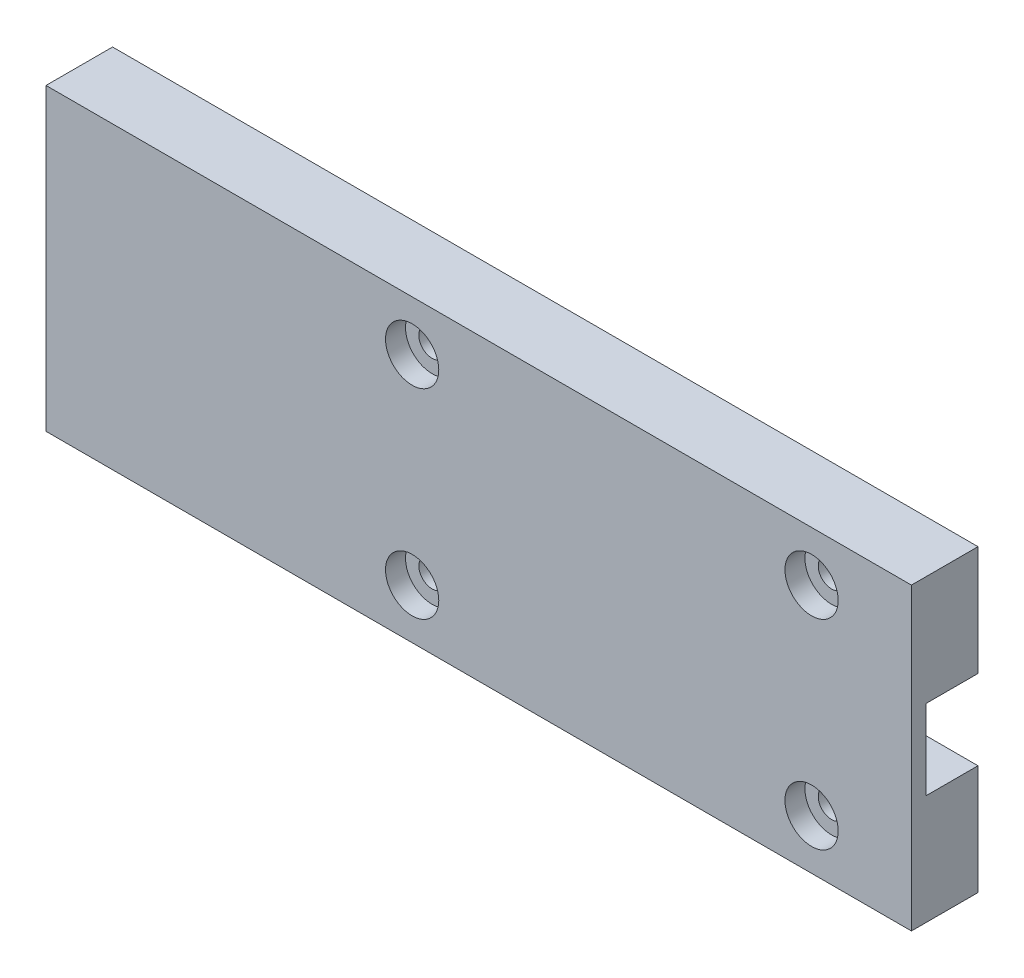
from build123d import *

# Parameters (mm, degrees)
SKETCH1_W           = 130
SKETCH1_H           = 45
BOSS_EXTRUDE1_DEPTH = 10
SKETCH2_W           = 110
SKETCH2_H           = 12
CUT_EXTRUDE1_DEPTH  = 7.8
SKETCH4_R           = 2
CUT_EXTRUDE3_DEPTH  = 11
SKETCH5_R           = 4
CUT_EXTRUDE4_DEPTH  = 3
SKETCH6_W           = 41
SKETCH6_H           = 41
CUT_EXTRUDE5_DEPTH  = 7.8


with BuildPart() as part:
    # Sketch1 → Boss-Extrude1 (new body)
    with BuildSketch(Plane.XY):
        with Locations((65, 22.5)):
            Rectangle(SKETCH1_W, SKETCH1_H)
    extrude(amount=BOSS_EXTRUDE1_DEPTH)

    # Sketch2 → Cut-Extrude1 (cut)
    with BuildSketch(Plane(origin=(0, 0, 0), x_dir=(-1, 0, 0), z_dir=(0, 0, -1))):
        with Locations((-75, 22.5)):
            Rectangle(SKETCH2_W, SKETCH2_H)
    extrude(amount=-CUT_EXTRUDE1_DEPTH, mode=Mode.SUBTRACT)

    # Sketch4 → Cut-Extrude3 (cut, through all)
    with BuildSketch(Plane.XY.offset(10)):
        with Locations((55, 37.5)):
            Circle(SKETCH4_R)
        with Locations((115, 37.5)):
            Circle(SKETCH4_R)
        with Locations((115, 7.5)):
            Circle(SKETCH4_R)
        with Locations((55, 7.5)):
            Circle(SKETCH4_R)
    extrude(amount=-CUT_EXTRUDE3_DEPTH, mode=Mode.SUBTRACT)

    # Sketch5 → Cut-Extrude4 (cut)
    with BuildSketch(Plane.XY.offset(10)):
        with Locations((55, 37.5)):
            Circle(SKETCH5_R)
        with Locations((115, 37.5)):
            Circle(SKETCH5_R)
        with Locations((115, 7.5)):
            Circle(SKETCH5_R)
        with Locations((55, 7.5)):
            Circle(SKETCH5_R)
    extrude(amount=-CUT_EXTRUDE4_DEPTH, mode=Mode.SUBTRACT)

    # Sketch6 → Cut-Extrude5 (cut)
    with BuildSketch(Plane(origin=(0, 0, 0), x_dir=(-1, 0, 0), z_dir=(0, 0, -1))):
        with Locations((-27, 22.5)):
            Rectangle(SKETCH6_W, SKETCH6_H)
    extrude(amount=-CUT_EXTRUDE5_DEPTH, mode=Mode.SUBTRACT)


solid = part.part
